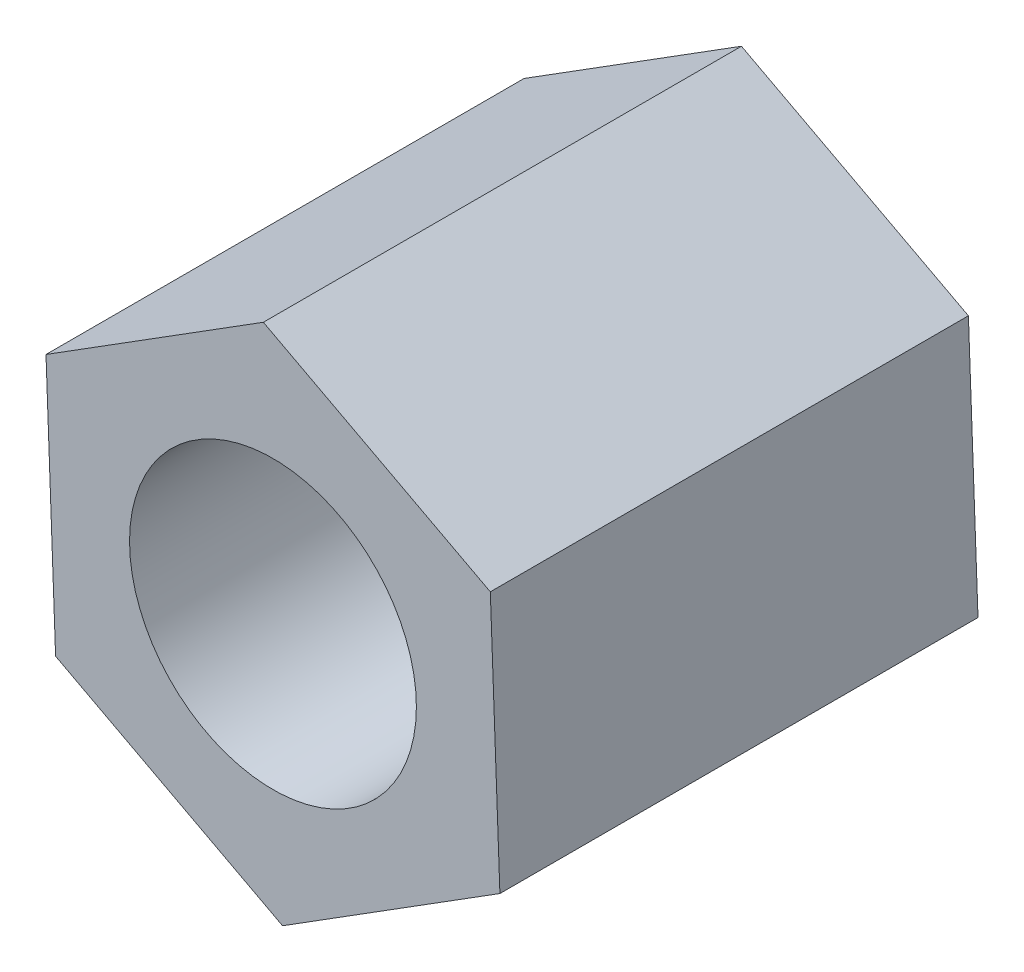
from build123d import *

# Parameters (mm, degrees)
SKETCH_1_R      = 1.5
EXTRUDE_1_DEPTH = 5


with BuildPart() as part:
    # 草图1 → 凸台-拉伸1 (new body)
    with BuildSketch(Plane.XY):
        Polygon((2.273206082, 1.428297627), (-0.100338988, 2.682803028), (-2.37354507, 1.254505402), (-2.273206082, -1.428297627), (0.100338988, -2.682803028), (2.37354507, -1.254505402), align=None)
        Circle(SKETCH_1_R, mode=Mode.SUBTRACT)
    extrude(amount=EXTRUDE_1_DEPTH)


solid = part.part
